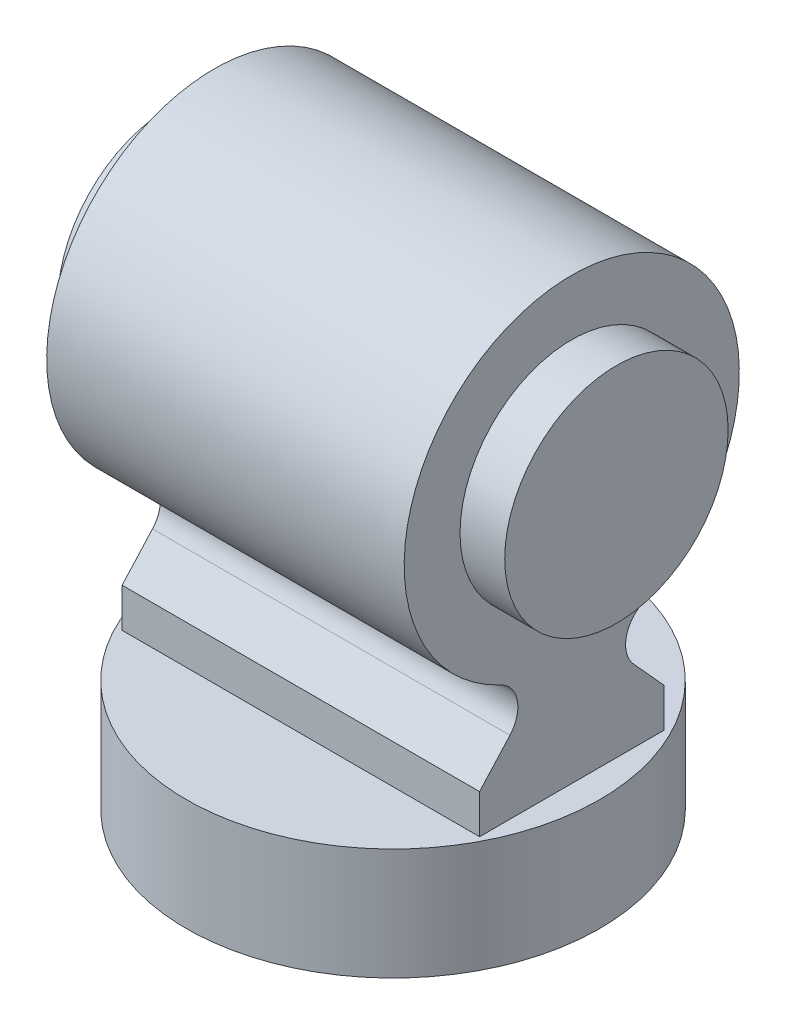
from build123d import *

# Parameters (mm, degrees)
BOSS_EXTRUDE1_DEPTH      = 32
BOSS_EXTRUDE1_DEPTH_BACK = 32
SKETCH3_R                = 20
BOSS_EXTRUDE2_DEPTH      = 8
SKETCH4_R                = 20
BOSS_EXTRUDE3_DEPTH      = 8
SKETCH5_R                = 37
BOSS_EXTRUDE4_DEPTH      = 20


with BuildPart() as part:
    # Sketch2 → Boss-Extrude1 (new body, two sides)
    with BuildSketch(Plane(origin=(0, 0, 0), x_dir=(0, 0, -1), z_dir=(1, 0, 0))) as boss_extrude1_sk:
        with BuildLine():
            Line((-11.058503278, -35.806497408), (-16.5, -41.82))
            Line((-16.5, -41.82), (-16.5, -48.82))
            Line((-16.5, -48.82), (16.5, -48.82))
            Line((16.5, -48.82), (16.5, -41.82))
            Line((16.5, -41.82), (11.058503278, -35.806497408))
            ThreePointArc((11.058503278, -35.806497408), (9.747712726, -31.031847175), (12.79921149, -27.132640587))
            ThreePointArc((12.79921149, -27.132640587), (0, 30), (-12.79921149, -27.132640587))
            ThreePointArc((-12.79921149, -27.132640587), (-9.747712726, -31.031847175), (-11.058503278, -35.806497408))
        make_face()
    extrude(amount=BOSS_EXTRUDE1_DEPTH)
    extrude(boss_extrude1_sk.sketch, amount=-BOSS_EXTRUDE1_DEPTH_BACK)

    # Sketch3 → Boss-Extrude2 (add)
    with BuildSketch(Plane(origin=(32, 0, 0), x_dir=(0, 0, -1), z_dir=(1, 0, 0))):
        Circle(SKETCH3_R)
    extrude(amount=BOSS_EXTRUDE2_DEPTH)

    # Sketch4 → Boss-Extrude3 (add)
    with BuildSketch(Plane.ZY.offset(32)):
        Circle(SKETCH4_R)
    extrude(amount=BOSS_EXTRUDE3_DEPTH)

    # Sketch5 → Boss-Extrude4 (add)
    with BuildSketch(Plane.XZ.offset(48.82)):
        Circle(SKETCH5_R)
    extrude(amount=BOSS_EXTRUDE4_DEPTH)


solid = part.part
